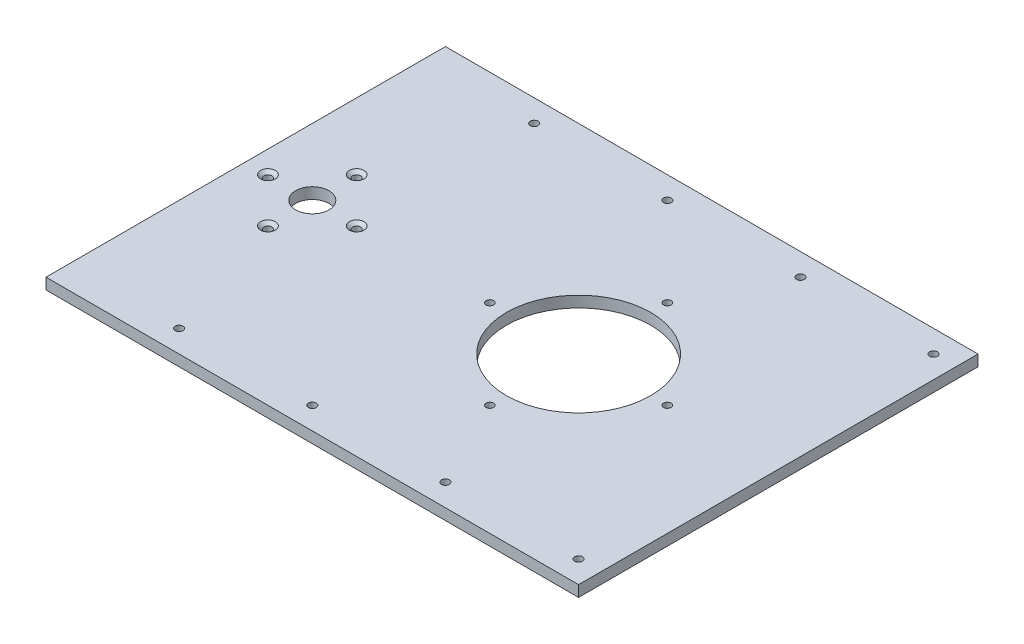
from build123d import *

# Parameters (mm, degrees)
SKETCH1_W                                         = 304.8
SKETCH1_H                                         = 228.6
BOSS_EXTRUDE1_DEPTH                               = 6.35
CSK_FOR_8_FLAT_HEAD_MACHINE_SCREW_100_D           = 4.3053
CSK_FOR_8_FLAT_HEAD_MACHINE_SCREW_100_CSINK_D     = 8.4328
CSK_FOR_8_FLAT_HEAD_MACHINE_SCREW_100_CSINK_ANGLE = 100
CIRPATTERN1_COUNT                                 = 4
SKETCH5_R                                         = 41.275
CUT_EXTRUDE1_DEPTH                                = 7.35
CSK_FOR_8_FLAT_HEAD_MACHINE_SCREW_2_D             = 4.4958
CSK_FOR_8_FLAT_HEAD_MACHINE_SCREW_2_CSINK_D       = 8.4328
CSK_FOR_8_FLAT_HEAD_MACHINE_SCREW_2_CSINK_ANGLE   = 100
LPATTERN1_COUNT                                   = 4
LPATTERN1_PITCH                                   = 76.2
SKETCH8_R                                         = 9.525
CUT_EXTRUDE2_DEPTH                                = 7.35
CSK_FOR_8_FLAT_HEAD_MACHINE_SCREW_3_D             = 4.4958
CSK_FOR_8_FLAT_HEAD_MACHINE_SCREW_3_CSINK_D       = 8.4328
CSK_FOR_8_FLAT_HEAD_MACHINE_SCREW_3_CSINK_ANGLE   = 100
CIRPATTERN2_COUNT                                 = 4


with BuildPart() as part:
    # Sketch1 → Boss-Extrude1 (new body)
    with BuildSketch(Plane(origin=(0, 0, 0), x_dir=(1, 0, 0), z_dir=(0, 1, 0))):
        with Locations((-152.4, 114.3)):
            Rectangle(SKETCH1_W, SKETCH1_H)
    extrude(amount=BOSS_EXTRUDE1_DEPTH)

    # CSK for _8 Flat Head Machine Screw _100 (through all)
    with Locations(Plane.XZ):
        with Locations((-114.3, -63.5)):
            csk_for_8_flat_head_machine_screw_100 = CounterSinkHole(CSK_FOR_8_FLAT_HEAD_MACHINE_SCREW_100_D / 2, CSK_FOR_8_FLAT_HEAD_MACHINE_SCREW_100_CSINK_D / 2, counter_sink_angle=CSK_FOR_8_FLAT_HEAD_MACHINE_SCREW_100_CSINK_ANGLE)

    # CirPattern1: CSK for _8 Flat Head Machine Screw _100 ×4 about axis
    cirpattern1_axis = Axis((-114.3, 0, -114.3), (0, 1, 0))
    for i in range(1, CIRPATTERN1_COUNT):
        add(csk_for_8_flat_head_machine_screw_100.rotate(cirpattern1_axis, i * 360 / CIRPATTERN1_COUNT), mode=Mode.SUBTRACT)

    # Sketch5 → Cut-Extrude1 (cut, through all)
    with BuildSketch(Plane(origin=(0, 6.35, 0), x_dir=(-1, 0, 0), z_dir=(0, 1, 0))):
        with Locations(Location((114.3, -114.3, 0), (0, 0, 90))):  # turned: the seam where the file's is
            Circle(SKETCH5_R)
    extrude(amount=-CUT_EXTRUDE1_DEPTH, mode=Mode.SUBTRACT)

    # CSK for _8 Flat Head Machine Screw _ 2 (through all)
    with Locations(Plane.XZ):
        with Locations((-12.7, -12.7), (-12.7, -215.9)):
            csk_for_8_flat_head_machine_screw_2 = CounterSinkHole(CSK_FOR_8_FLAT_HEAD_MACHINE_SCREW_2_D / 2, CSK_FOR_8_FLAT_HEAD_MACHINE_SCREW_2_CSINK_D / 2, counter_sink_angle=CSK_FOR_8_FLAT_HEAD_MACHINE_SCREW_2_CSINK_ANGLE)

    # LPattern1: CSK for _8 Flat Head Machine Screw _ 2 ×4
    with Locations(*[(-i * LPATTERN1_PITCH, 0, 0) for i in range(1, LPATTERN1_COUNT)]):
        add(csk_for_8_flat_head_machine_screw_2, mode=Mode.SUBTRACT)

    # Sketch8 → Cut-Extrude2 (cut, through all)
    with BuildSketch(Plane(origin=(0, 6.35, 0), x_dir=(1, 0, 0), z_dir=(0, 1, 0))):
        with Locations(Location((-266.7, 114.3, 0), (0, 0, 270))):  # turned: the seam where the file's is
            Circle(SKETCH8_R)
    extrude(amount=-CUT_EXTRUDE2_DEPTH, mode=Mode.SUBTRACT)

    # CSK for _8 Flat Head Machine Screw _ 3 (through all)
    with Locations(Plane(origin=(13.285571089, 6.35, -61.700466349), x_dir=(1, 0, 0), z_dir=(0, 1, 0))):
        with Locations((-305.385571089, 52.599533651)):
            csk_for_8_flat_head_machine_screw_3 = CounterSinkHole(CSK_FOR_8_FLAT_HEAD_MACHINE_SCREW_3_D / 2, CSK_FOR_8_FLAT_HEAD_MACHINE_SCREW_3_CSINK_D / 2, counter_sink_angle=CSK_FOR_8_FLAT_HEAD_MACHINE_SCREW_3_CSINK_ANGLE)

    # CirPattern2: CSK for _8 Flat Head Machine Screw _ 3 ×4 about axis
    cirpattern2_axis = Axis((-266.7, 0, -114.3), (0, 1, 0))
    for i in range(1, CIRPATTERN2_COUNT):
        add(csk_for_8_flat_head_machine_screw_3.rotate(cirpattern2_axis, i * 360 / CIRPATTERN2_COUNT), mode=Mode.SUBTRACT)


solid = part.part
